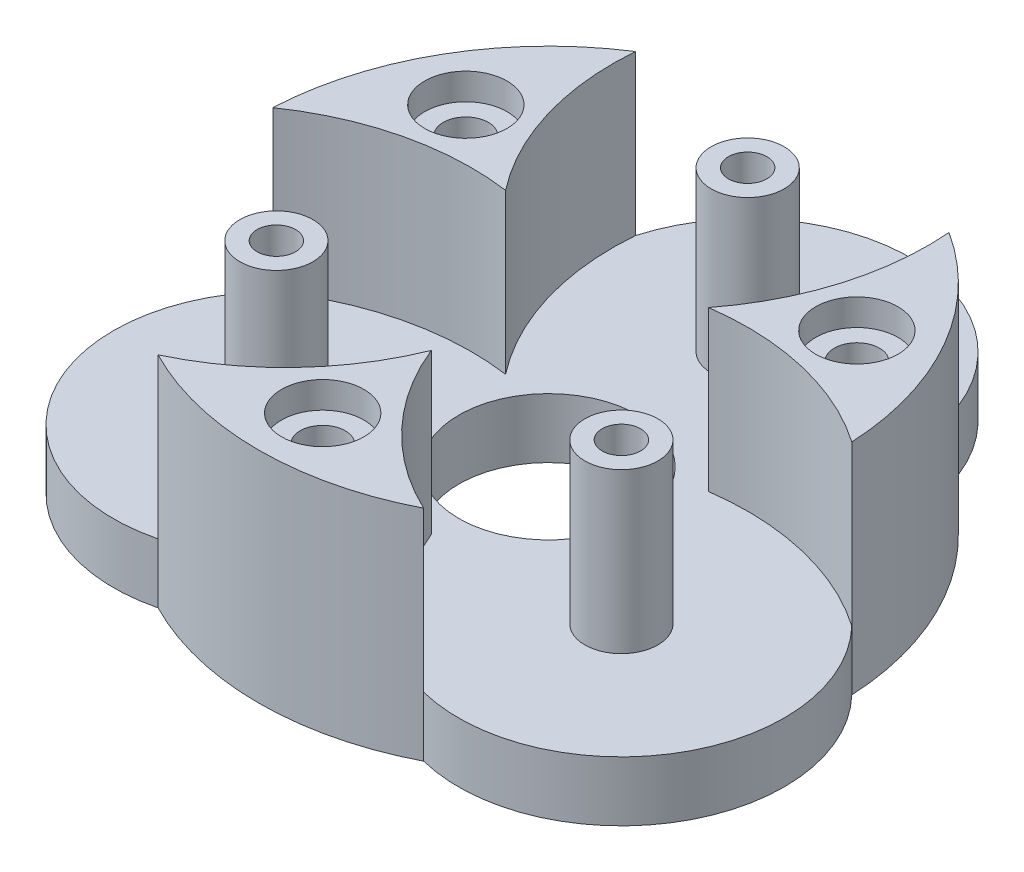
from build123d import *

# Parameters (mm, degrees)
CROQUIS1_R                     = 21.825
SALIENTE_EXTRUIR1_DEPTH        = 4.5
CROQUIS2_R                     = 2.75
SALIENTE_EXTRUIR2_DEPTH        = 12
TALADRO_DE_MARGEN_PARA_M121_D  = 13.5
SALIENTE_EXTRUIR3_DEPTH        = 12
CROQUIS8_R                     = 1.7
CORTAR_EXTRUIR1_DEPTH          = 16.5
MATRIZC1_COUNT                 = 3
TALADRO_DE_MARGEN_PARA_M2_51_D = 2.9
SALIENTE_EXTRUIR5_DEPTH        = 4.5
MATRIZC2_COUNT                 = 3
CROQUIS12_R                    = 2.875
CORTAR_EXTRUIR2_DEPTH          = 2.2
CROQUIS13_R                    = 3.1
CORTAR_EXTRUIR3_DEPTH          = 2


with BuildPart() as part:
    # Croquis1 → Saliente-Extruir1 (new body)
    with BuildSketch(Plane(origin=(0, 0, 0), x_dir=(1, 0, 0), z_dir=(0, 1, 0))):
        Circle(CROQUIS1_R)
    extrude(amount=SALIENTE_EXTRUIR1_DEPTH)

    # Croquis2 → Saliente-Extruir2 (add)
    with BuildSketch(Plane(origin=(0, 4.5, 0), x_dir=(1, 0, 0), z_dir=(0, 1, 0))):
        with Locations((0, 15)):
            Circle(CROQUIS2_R)
        with Locations((12.990381057, -7.5)):
            Circle(CROQUIS2_R)
        with Locations((-12.990381057, -7.5)):
            Circle(CROQUIS2_R)
    extrude(amount=SALIENTE_EXTRUIR2_DEPTH)

    # Taladro de margen para M121 (through all)
    with Locations(Plane(origin=(0, 4.5, 0), x_dir=(1, 0, 0), z_dir=(0, 1, 0))):
        with Locations((0, 0)):
            Hole(TALADRO_DE_MARGEN_PARA_M121_D / 2)

    # Croquis5 → Saliente-Extruir3 (add)
    with BuildSketch(Plane(origin=(0, 4.5, 0), x_dir=(1, 0, 0), z_dir=(0, 1, 0))):
        with BuildLine():
            ThreePointArc((-7.642674188, 4.4125), (-11.035446071, 10.994501306), (-11.800237164, 18.359875487))
            ThreePointArc((-11.800237164, 18.359875487), (-18.901004438, 10.9125), (-21.800237164, 1.039367411))
            ThreePointArc((-21.800237164, 1.039367411), (-15.039240468, 4.059725986), (-7.642674188, 4.4125))
        make_face()
    saliente_extruir3 = extrude(amount=SALIENTE_EXTRUIR3_DEPTH)

    # Croquis8 → Cortar-Extruir1 (cut)
    with BuildSketch(Plane(origin=(0, 16.5, 0), x_dir=(1, 0, 0), z_dir=(0, 1, 0))):
        with Locations((-14.722431864, 8.5)):
            Circle(CROQUIS8_R)
    cortar_extruir1 = extrude(amount=-CORTAR_EXTRUIR1_DEPTH, mode=Mode.SUBTRACT)

    # MatrizC1: Saliente-Extruir3, Cortar-Extruir1 ×3 about axis
    matrizc1_axis = Axis((0, 0, 0), (0, 1, 0))
    for i in range(1, MATRIZC1_COUNT):
        add(saliente_extruir3.rotate(matrizc1_axis, i * 360 / MATRIZC1_COUNT))
        add(cortar_extruir1.rotate(matrizc1_axis, i * 360 / MATRIZC1_COUNT), mode=Mode.SUBTRACT)

    # Taladro de margen para M2.51 (through all)
    with Locations(Plane(origin=(0, 16.5, 0), x_dir=(1, 0, 0), z_dir=(0, 1, 0))):
        with Locations((12.990381057, -7.5), (-12.990381057, -7.5), (0, 15)):
            Hole(TALADRO_DE_MARGEN_PARA_M2_51_D / 2)

    # Croquis11 → Saliente-Extruir5 (add)
    with BuildSketch(Plane.XZ):
        with BuildLine():
            ThreePointArc((-10, 19.399242898), (-18.901004438, 10.9125), (-21.800237164, -1.039367411))
            ThreePointArc((-21.800237164, -1.039367411), (-23.615858472, 13.634622246), (-10, 19.399242898))
        make_face()
    saliente_extruir5 = extrude(amount=-SALIENTE_EXTRUIR5_DEPTH)

    # MatrizC2: Saliente-Extruir5 ×3 about axis
    matrizc2_axis = Axis((0, 0, 0), (0, 1, 0))
    for i in range(1, MATRIZC2_COUNT):
        add(saliente_extruir5.rotate(matrizc2_axis, i * 360 / MATRIZC2_COUNT))

    # Croquis12 → Cortar-Extruir2 (cut)
    with BuildSketch(Plane.XZ):
        with Locations((-12.990381057, 7.5)):
            Circle(CROQUIS12_R)
        with Locations((12.990381057, 7.5)):
            Circle(CROQUIS12_R)
        with Locations((0, -15)):
            Circle(CROQUIS12_R)
    extrude(amount=-CORTAR_EXTRUIR2_DEPTH, mode=Mode.SUBTRACT)

    # Croquis13 → Cortar-Extruir3 (cut)
    with BuildSketch(Plane(origin=(0, 16.5, 0), x_dir=(1, 0, 0), z_dir=(0, 1, 0))):
        with Locations((0, -17)):
            Circle(CROQUIS13_R)
        with Locations((-14.722431864, 8.5)):
            Circle(CROQUIS13_R)
        with Locations((14.722431864, 8.5)):
            Circle(CROQUIS13_R)
    extrude(amount=-CORTAR_EXTRUIR3_DEPTH, mode=Mode.SUBTRACT)


solid = part.part
